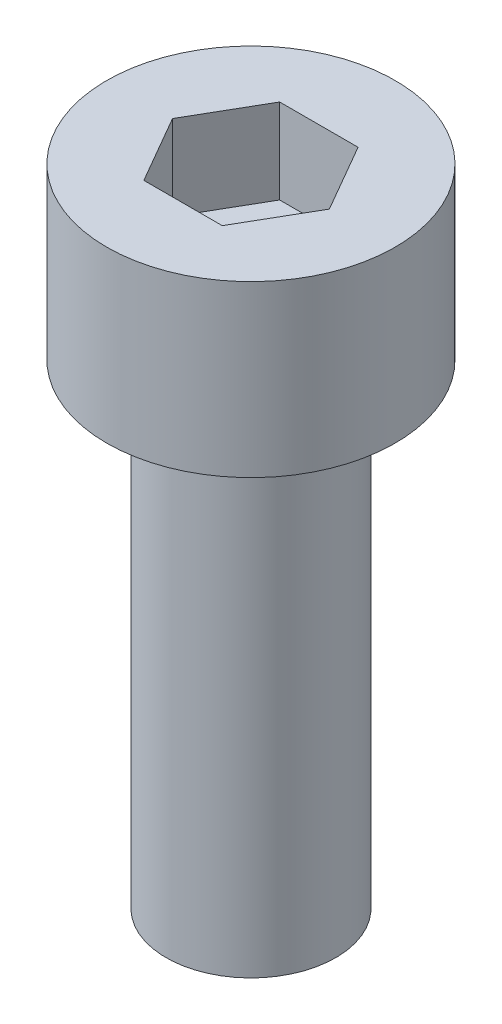
from build123d import *

# Parameters (mm, degrees)
SKETCH_1_R          = 4.25
EXTRUDE_1_DEPTH     = 5
CUT_EXTRUDE_1_DEPTH = 2.5
SKETCH_3_R          = 2.5
EXTRUDE_2_DEPTH     = 14


with BuildPart() as part:
    # 草图1 → 凸台-拉伸1 (new body)
    with BuildSketch(Plane(origin=(0, 0, 0), x_dir=(1, 0, 0), z_dir=(0, 1, 0))):
        Circle(SKETCH_1_R)
    extrude(amount=EXTRUDE_1_DEPTH)

    # 草图2 → 切除-拉伸1 (cut)
    with BuildSketch(Plane(origin=(0, 5, 0), x_dir=(1, 0, 0), z_dir=(0, 1, 0))):
        Polygon((2.309401077, 0), (1.154700538, 2), (-1.154700538, 2), (-2.309401077, 0), (-1.154700538, -2), (1.154700538, -2), align=None)
    extrude(amount=-CUT_EXTRUDE_1_DEPTH, mode=Mode.SUBTRACT)

    # 草图3 → 凸台-拉伸2 (add)
    with BuildSketch(Plane.XZ):
        Circle(SKETCH_3_R)
    extrude(amount=EXTRUDE_2_DEPTH)


solid = part.part
